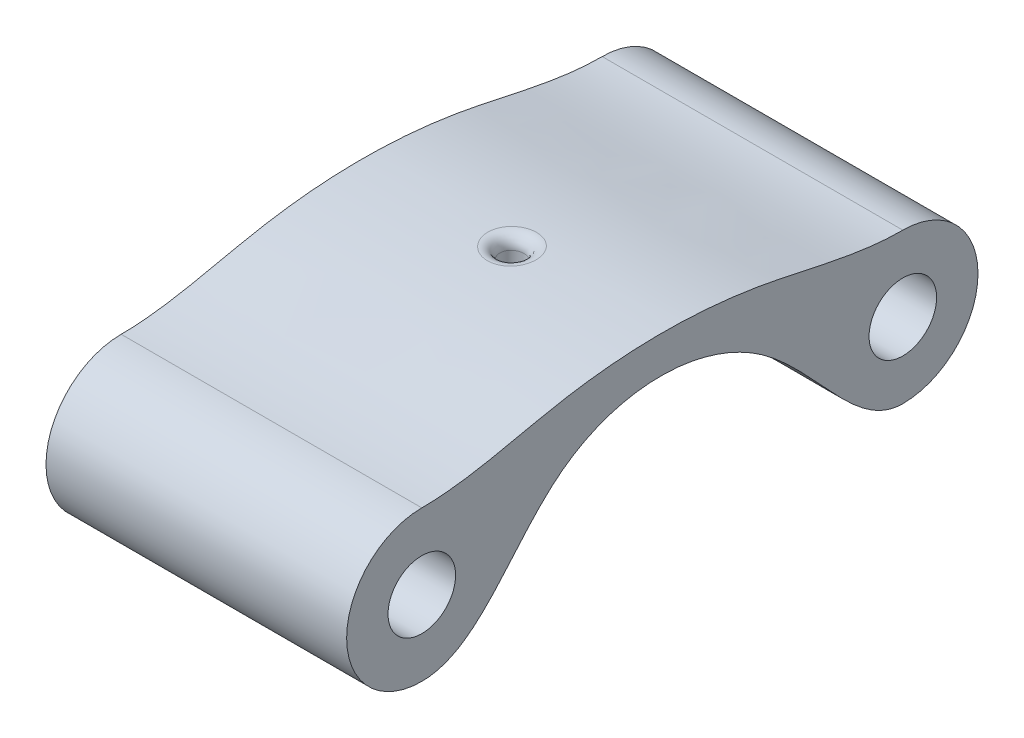
from build123d import *

# Parameters (mm, degrees)
SKETCH1_R               = 3.5687
BOSS_EXTRUDE1_DEPTH     = 15.875
SKETCH3_R               = 1.27
CUT_EXTRUDE1_DEPTH      = 10.664482261
CUT_EXTRUDE1_DEPTH_BACK = 10.5250001
FILLET1_R               = 1.27


with BuildPart() as part:
    # Sketch1 → Boss-Extrude1 (new body, symmetric)
    with BuildSketch(Plane(origin=(0, 0, 0), x_dir=(0, 0, -1), z_dir=(1, 0, 0))):
        with BuildLine():
            ThreePointArc((-25.4, 6.35), (-33.3375, -1.5875), (-25.4, -9.525))
            add(Edge.make_bspline(
                [(-25.4, -9.525), (-19.285597161, -9.525), (-12.305997333, 6.920563629), (11.89065455, 6.920563629), (20.378521675, -9.525), (25.4, -9.525)],
                knots=[0, 0, 0, 0, 0.322142276, 0.677857724, 1, 1, 1, 1], degree=3))
            ThreePointArc((25.4, -9.525), (33.3375, -1.5875), (25.4, 6.35))
            add(Edge.make_bspline(
                [(-25.4, 6.35), (-20.376566451, 6.35), (-8.675332264, 9.972034061), (8.633848157, 9.972034061), (20.457221768, 6.35), (25.4, 6.35)],
                knots=[0, 0, 0, 0, 0.294387704, 0.705612296, 1, 1, 1, 1], degree=3))
        make_face()
        with Locations((-25.4, -1.5875)):
            Circle(SKETCH1_R, mode=Mode.SUBTRACT)
        with Locations((25.4, -1.5875)):
            Circle(SKETCH1_R, mode=Mode.SUBTRACT)
    extrude(amount=BOSS_EXTRUDE1_DEPTH, both=True)

    # Sketch3 → Cut-Extrude1 (cut, two sides)
    with BuildSketch(Plane(origin=(0, 0, 0), x_dir=(1, 0, 0), z_dir=(0, 1, 0))) as cut_extrude1_sk:
        Circle(SKETCH3_R)
    extrude(amount=CUT_EXTRUDE1_DEPTH, mode=Mode.SUBTRACT)
    extrude(cut_extrude1_sk.sketch, amount=-CUT_EXTRUDE1_DEPTH_BACK, mode=Mode.SUBTRACT)

    # Fillet1
    fillet1_edges = [part.edges().sort_by_distance(p)[0] for p in [
        (0.898025647, 9.657580455, -0.898025583),
    ]]
    fillet(fillet1_edges, radius=FILLET1_R)


solid = part.part
